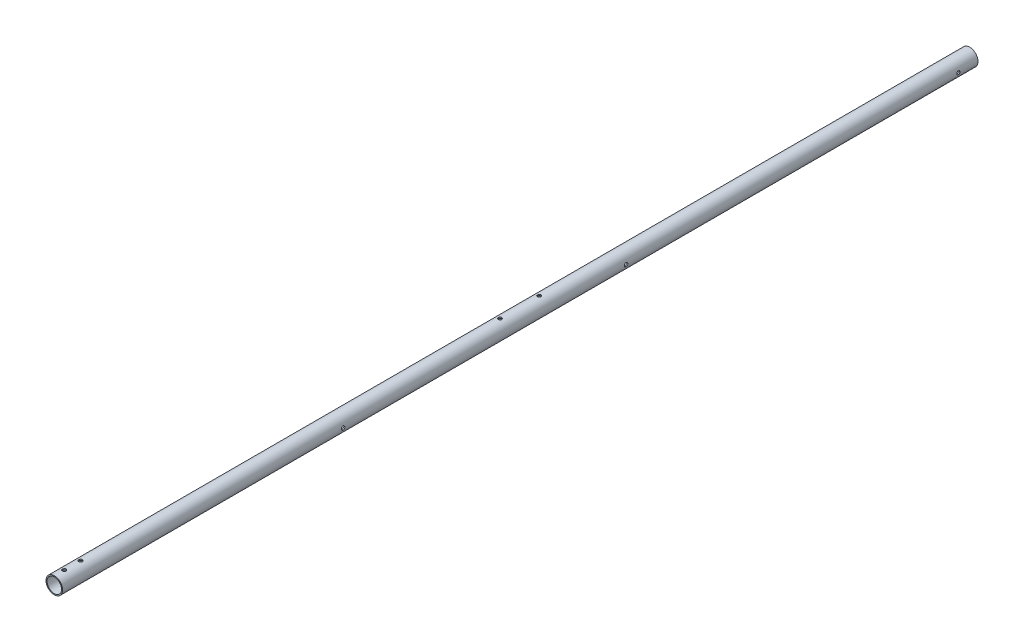
from build123d import *

# Parameters (mm, degrees)
SKETCH2_R                     = 12.7
SKETCH2_R_2                   = 11.1125
BOSS_EXTRUDE1_DEPTH           = 1400
SKETCH6_W                     = 2.75
SKETCH6_H                     = 12.7
M5_CLEARANCE_HOLE1_AT_2_COUNT = 2
M5_CLEARANCE_HOLE1_AT_2_PITCH = 25
MIRROR1_COPY_1_SKETCH_W       = 2.75
MIRROR1_COPY_1_SKETCH_H       = 12.7
SKETCH7_R                     = 2.65
CUT_EXTRUDE1_DEPTH            = 13.7000001
CUT_EXTRUDE1_DEPTH_BACK       = 13.7000001
SKETCH8_R                     = 2.5
CUT_EXTRUDE2_DEPTH            = 13.7000001
CUT_EXTRUDE2_DEPTH_BACK       = 13.7000001
SKETCH9_R                     = 2.75
CUT_EXTRUDE3_DEPTH            = 13.7000001
CUT_EXTRUDE3_DEPTH_BACK       = 13.7000001


with BuildPart() as part:
    # Sketch2 → Boss-Extrude1 (new body)
    with BuildSketch(Plane.XY):
        Circle(SKETCH2_R)
        Circle(SKETCH2_R_2, mode=Mode.SUBTRACT)
    extrude(amount=BOSS_EXTRUDE1_DEPTH)

    # Sketch6 → M5 Clearance Hole1 (revolve, cut)
    with BuildSketch(Plane(origin=(0, 0, 1385), x_dir=(0, 0, -1), z_dir=(1, 0, 0))):
        with Locations((1.375, 6.35)):
            Rectangle(SKETCH6_W, SKETCH6_H)
    m5_clearance_hole1 = revolve(axis=Axis((0, -6.35, 1385), (0, 1, 0)), mode=Mode.SUBTRACT)

    # M5 Clearance Hole1 at 2: M5 Clearance Hole1 ×2
    with Locations(*[(0, 0, -i * M5_CLEARANCE_HOLE1_AT_2_PITCH) for i in range(1, M5_CLEARANCE_HOLE1_AT_2_COUNT)]):
        add(m5_clearance_hole1, mode=Mode.SUBTRACT)

    # Mirror1: M5 Clearance Hole1 across plane
    add(m5_clearance_hole1.mirror(Plane.ZX), mode=Mode.SUBTRACT)

    # Mirror1 copy 1 sketch → Mirror1 copy 1 (revolve, cut)
    with BuildSketch(Plane(origin=(0, 0, 1360), x_dir=(0, 0, -1), z_dir=(1, 0, 0))):
        with Locations((1.375, -6.35)):
            Rectangle(MIRROR1_COPY_1_SKETCH_W, MIRROR1_COPY_1_SKETCH_H)
    revolve(axis=Axis((0, 6.35, 1360), (0, 1, 0)), mode=Mode.SUBTRACT)

    # Sketch7 → Cut-Extrude1 (cut, two sides)
    with BuildSketch(Plane(origin=(0, 0, 0), x_dir=(1, 0, 0), z_dir=(0, 1, 0))) as cut_extrude1_sk:
        with Locations((0, -658.455209615)):
            Circle(SKETCH7_R)
        with Locations((0, -718.455209615)):
            Circle(SKETCH7_R)
    extrude(amount=CUT_EXTRUDE1_DEPTH, mode=Mode.SUBTRACT)
    extrude(cut_extrude1_sk.sketch, amount=-CUT_EXTRUDE1_DEPTH_BACK, mode=Mode.SUBTRACT)

    # Sketch8 → Cut-Extrude2 (cut, two sides)
    with BuildSketch(Plane(origin=(0, 0, 0), x_dir=(0, 0, -1), z_dir=(1, 0, 0))) as cut_extrude2_sk:
        with Locations((-30, 0)):
            Circle(SKETCH8_R)
    extrude(amount=CUT_EXTRUDE2_DEPTH, mode=Mode.SUBTRACT)
    extrude(cut_extrude2_sk.sketch, amount=-CUT_EXTRUDE2_DEPTH_BACK, mode=Mode.SUBTRACT)

    # Sketch9 → Cut-Extrude3 (cut, two sides)
    with BuildSketch(Plane(origin=(0, 0, 0), x_dir=(0, 0, -1), z_dir=(1, 0, 0))) as cut_extrude3_sk:
        with Locations((-538.254950935, 0)):
            Circle(SKETCH9_R)
        with Locations((-970.955209615, 0)):
            Circle(SKETCH9_R)
    extrude(amount=CUT_EXTRUDE3_DEPTH, mode=Mode.SUBTRACT)
    extrude(cut_extrude3_sk.sketch, amount=-CUT_EXTRUDE3_DEPTH_BACK, mode=Mode.SUBTRACT)


solid = part.part
